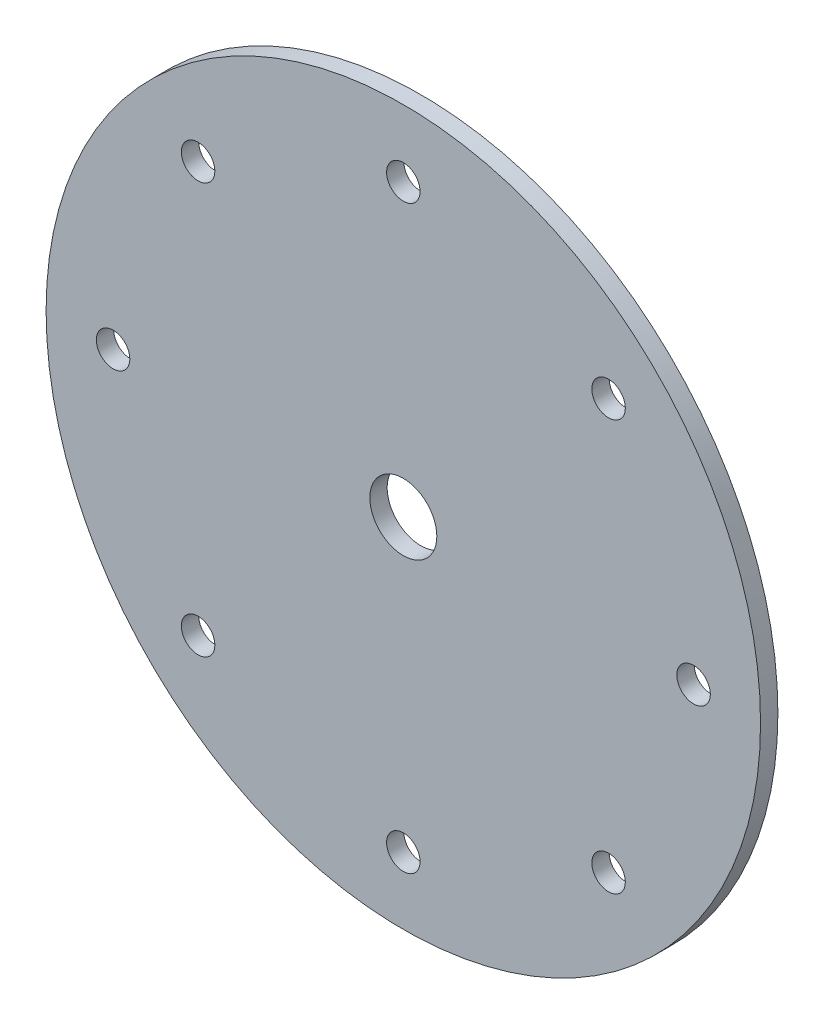
from build123d import *

# Parameters (mm, degrees)
SKETCH1_R        = 101.6
SKETCH1_R_2      = 9.525
SKETCH1_R_3      = 4.7625
ROTOR_DISC_DEPTH = 4.93522


with BuildPart() as part:
    # Sketch1 → Rotor Disc (new body)
    with BuildSketch(Plane.XY):
        Circle(SKETCH1_R)
        Circle(SKETCH1_R_2, mode=Mode.SUBTRACT)
        with Locations((0, 82.55)):
            Circle(SKETCH1_R_3, mode=Mode.SUBTRACT)
        with Locations((58.371664787, 58.371664787)):
            Circle(SKETCH1_R_3, mode=Mode.SUBTRACT)
        with Locations((82.55, 0)):
            Circle(SKETCH1_R_3, mode=Mode.SUBTRACT)
        with Locations((58.371664787, -58.371664787)):
            Circle(SKETCH1_R_3, mode=Mode.SUBTRACT)
        with Locations((0, -82.55)):
            Circle(SKETCH1_R_3, mode=Mode.SUBTRACT)
        with Locations((-58.371664787, -58.371664787)):
            Circle(SKETCH1_R_3, mode=Mode.SUBTRACT)
        with Locations((-82.55, 0)):
            Circle(SKETCH1_R_3, mode=Mode.SUBTRACT)
        with Locations((-58.371664787, 58.371664787)):
            Circle(SKETCH1_R_3, mode=Mode.SUBTRACT)
    extrude(amount=ROTOR_DISC_DEPTH)


solid = part.part
